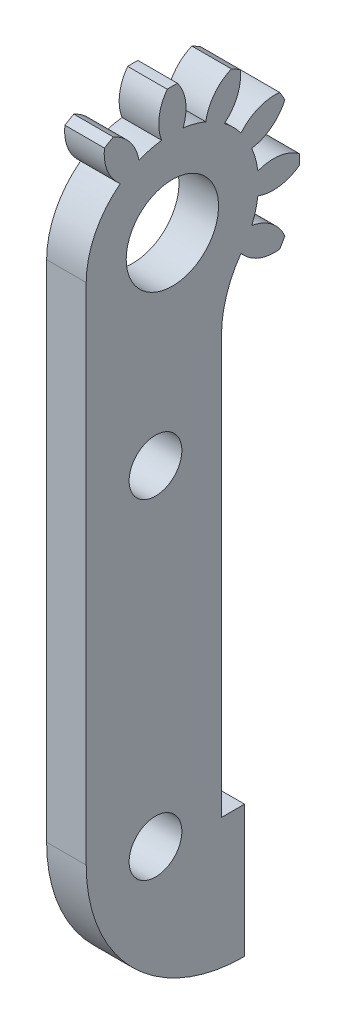
from build123d import *

# Parameters (mm, degrees)
CROQUIS1_R              = 2
CROQUIS1_R_2            = 3.5
SALIENTE_EXTRUIR1_DEPTH = 3


with BuildPart() as part:
    # Croquis1 → Saliente-Extruir1 (new body)
    with BuildSketch(Plane(origin=(2.816112381, 0, 0), x_dir=(0, 0, -1), z_dir=(1, 0, 0))):
        with BuildLine():
            Line((-6.304052244, 0.230126664), (-6.304052244, -38))
            ThreePointArc((-6.304052244, -38), (-2.789333619, -46.485281374), (5.695947756, -50))
            Line((5.695947756, -50), (5.695947756, -40))
            Line((5.695947756, -40), (3.945947756, -40))
            Line((3.945947756, -40), (3.945947756, -8.356393503))
            ThreePointArc((3.945947756, -8.356393503), (4.325796585, -5.920557684), (5.42927179, -3.716034211))
            ThreePointArc((5.42927179, -3.716034211), (6.741018488, -4.690759176), (8.359590341, -4.916576169))
            ThreePointArc((8.359590341, -4.916576169), (8.561692267, -4.582373336), (8.750069448, -4.240246517))
            ThreePointArc((8.750069448, -4.240246517), (7.745220269, -2.951430671), (6.245210338, -2.302787189))
            ThreePointArc((6.245210338, -2.302787189), (6.533934883, -1.460026405), (6.705272485, -0.585811884))
            ThreePointArc((6.705272485, -0.585811884), (8.328640931, -0.774075116), (9.84327377, -0.160352443))
            ThreePointArc((9.84327377, -0.160352443), (9.851197756, 0.230126664), (9.84327377, 0.620605771))
            ThreePointArc((9.84327377, 0.620605771), (8.328640931, 1.234328445), (6.705272485, 1.046065213))
            ThreePointArc((6.705272485, 1.046065213), (6.533934883, 1.920279734), (6.245210338, 2.763040518))
            ThreePointArc((6.245210338, 2.763040518), (7.745220269, 3.411683999), (8.750069448, 4.700499845))
            ThreePointArc((8.750069448, 4.700499845), (8.561692267, 5.042626664), (8.359590341, 5.376829498))
            ThreePointArc((8.359590341, 5.376829498), (6.741018488, 5.151012505), (5.42927179, 4.17628754))
            ThreePointArc((5.42927179, 4.17628754), (4.843781813, 4.847710722), (4.172358631, 5.433200699))
            ThreePointArc((4.172358631, 5.433200699), (5.147083596, 6.744947397), (5.372900589, 8.363519249))
            ThreePointArc((5.372900589, 8.363519249), (5.038697756, 8.565621176), (4.696570936, 8.753998356))
            ThreePointArc((4.696570936, 8.753998356), (3.407755091, 7.749149177), (2.759111609, 6.249139247))
            ThreePointArc((2.759111609, 6.249139247), (1.916350825, 6.537863791), (1.042136304, 6.709201394))
            ThreePointArc((1.042136304, 6.709201394), (1.230399536, 8.33256984), (0.616676863, 9.847202679))
            ThreePointArc((0.616676863, 9.847202679), (0.226197756, 9.855126664), (-0.164281352, 9.847202679))
            ThreePointArc((-0.164281352, 9.847202679), (-0.778004025, 8.33256984), (-0.589740793, 6.709201394))
            ThreePointArc((-0.589740793, 6.709201394), (-1.463955314, 6.537863791), (-2.306716098, 6.249139247))
            ThreePointArc((-2.306716098, 6.249139247), (-2.95535958, 7.749149177), (-4.244175425, 8.753998356))
            ThreePointArc((-4.244175425, 8.753998356), (-4.586302244, 8.565621176), (-4.920505078, 8.363519249))
            ThreePointArc((-4.920505078, 8.363519249), (-4.694688085, 6.744947397), (-3.71996312, 5.433200699))
            ThreePointArc((-3.71996312, 5.433200699), (-5.622459446, 3.134842486), (-6.304052244, 0.230126664))
        make_face()
        with Locations((-1.054052244, -14.410797367)):
            Circle(CROQUIS1_R, mode=Mode.SUBTRACT)
        with Locations((-1.054052244, -39.410797367)):
            Circle(CROQUIS1_R, mode=Mode.SUBTRACT)
        with Locations((0.226197756, 0.230126664)):
            Circle(CROQUIS1_R_2, mode=Mode.SUBTRACT)
    extrude(amount=-SALIENTE_EXTRUIR1_DEPTH)


solid = part.part
